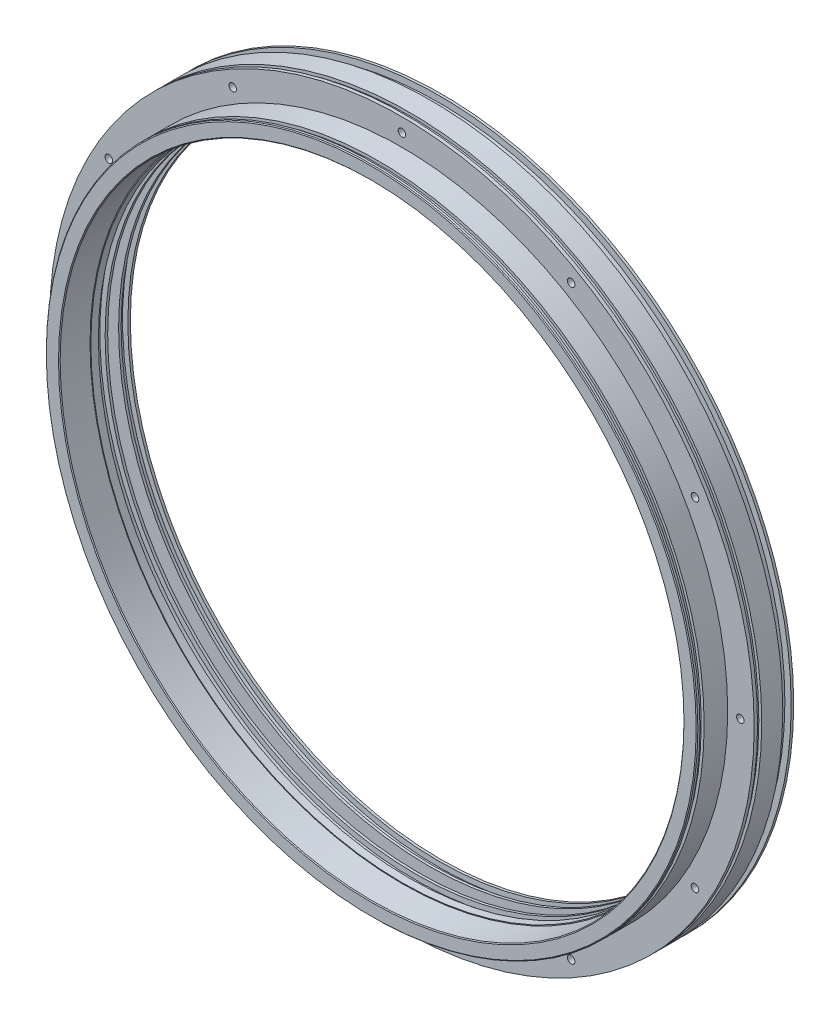
from build123d import *

# Parameters (mm, degrees)
FASE1_SIZE         = 1
KREISMUSTER1_COUNT = 12


with BuildPart() as part:
    # Skizze1 → Rotation1 (revolve)
    with BuildSketch(Plane(origin=(0, 0, 0), x_dir=(0, 0, -1), z_dir=(1, 0, 0)), mode=Mode.PRIVATE) as rotation1_sk:
        Polygon((0, 371), (0, 387.5), (3.5, 387.5), (3.5, 384), (8.5, 384), (8.5, 387.5), (36.5, 387.5), (36.5, 419), (40.5, 419), (40.5, 415.5), (45.5, 415.5), (45.5, 419), (70.5, 419), (70.5, 411.5), (80.5, 411.5), (80.5, 419), (83.5, 419), (83.5, 370), (80.5, 370), (80.5, 376.3), (72.5, 376.3), (72.5, 370), (69.5, 370), (69.5, 393.8), (56.5, 393.8), (56.5, 370), (53.5, 370), (53.5, 376.3), (45.5, 376.3), (45.5, 370), (36.5, 370), (36.5, 371), align=None)
    revolve(rotation1_sk.sketch.rotate(Axis((0, 0, 0), (0, 0, -1)), 90), axis=Axis((0, 0, 0), (0, 0, -1)))  # turned: the seam where the file's is

    # Fase1
    fase1_edges = [part.edges().sort_by_distance(p)[0] for p in [
        (-371, 0, 0),
        (-387.5, 0, 0),
    ]]
    chamfer(fase1_edges, length=FASE1_SIZE)

    # Skizze3 → Bohrung1 (revolve, cut)
    with BuildSketch(Plane(origin=(0, 402.5, -83.5), x_dir=(0, 1, 0), z_dir=(1, 0, 0))):
        Polygon((0, 0), (0, 86.203872786), (4.5, 83.5), (4.5, 9), (7.5, 9), (7.5, 0), align=None)
    bohrung1 = revolve(axis=Axis((0, 402.5, -94.810875039), (0, 0, 1)), mode=Mode.SUBTRACT)

    # Kreismuster1: Bohrung1 ×12 about axis
    kreismuster1_axis = Axis((0, 0, 0), (0, 0, 1))
    for i in range(1, KREISMUSTER1_COUNT):
        add(bohrung1.rotate(kreismuster1_axis, i * 360 / KREISMUSTER1_COUNT), mode=Mode.SUBTRACT)


solid = part.part
